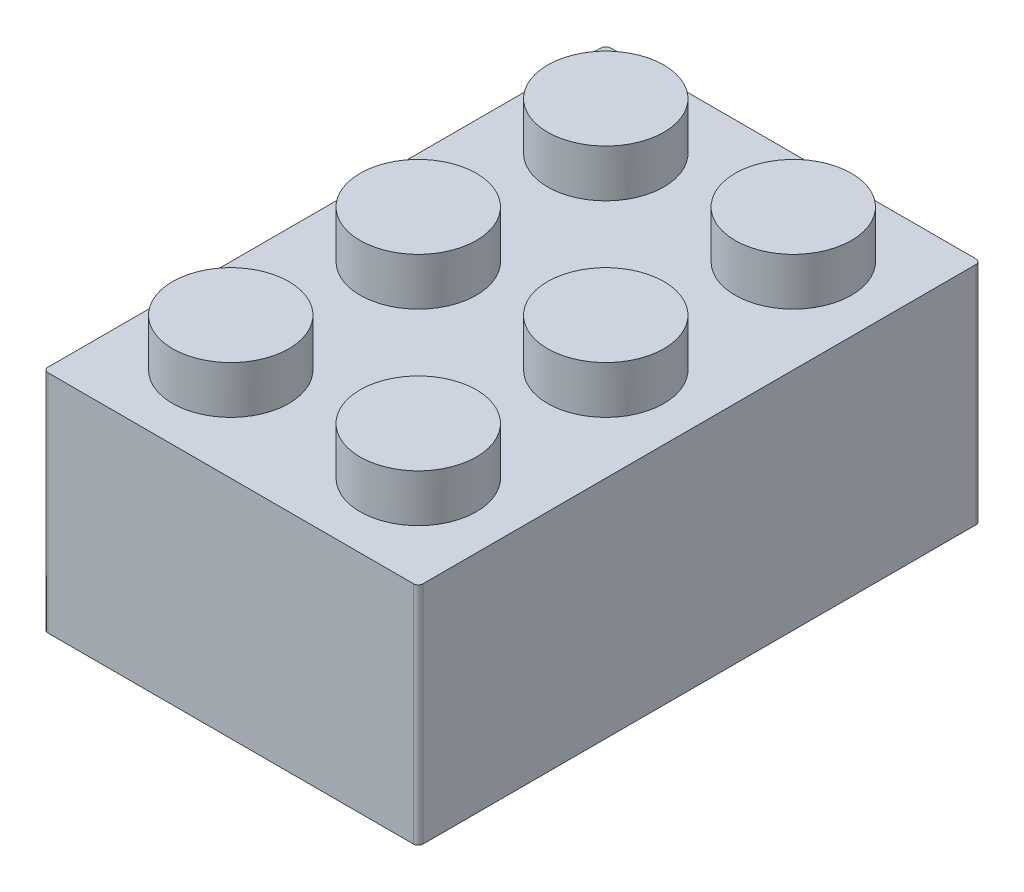
from build123d import *

# Parameters (mm, degrees)
SKETCH1_W           = 15.8
SKETCH1_H           = 23.7
BOSS_EXTRUDE1_DEPTH = 4.75
SKETCH2_R           = 2.45
BOSS_EXTRUDE2_DEPTH = 2
SKETCH4_W           = 12.8
SKETCH4_H           = 20.7
CUT_EXTRUDE1_DEPTH  = 4
SKETCH5_R           = 3.25
SKETCH5_R_2         = 2.45
BOSS_EXTRUDE3_DEPTH = 4
FILLET1_R           = 0.2


with BuildPart() as part:
    # Sketch1 → Boss-Extrude1 (new body, symmetric)
    with BuildSketch(Plane(origin=(0, 0, 0), x_dir=(1, 0, 0), z_dir=(0, 1, 0))):
        with Locations((7.9, 11.85)):
            Rectangle(SKETCH1_W, SKETCH1_H)
    extrude(amount=BOSS_EXTRUDE1_DEPTH, both=True)

    # Sketch2 → Boss-Extrude2 (add)
    with BuildSketch(Plane(origin=(0, 4.75, 0), x_dir=(1, 0, 0), z_dir=(0, 1, 0))):
        with Locations((3.95, 3.95)):
            Circle(SKETCH2_R)
        with Locations((11.85, 3.95)):
            Circle(SKETCH2_R)
        with Locations((11.85, 11.85)):
            Circle(SKETCH2_R)
        with Locations((3.95, 11.85)):
            Circle(SKETCH2_R)
        with Locations((3.95, 19.75)):
            Circle(SKETCH2_R)
        with Locations((11.85, 19.75)):
            Circle(SKETCH2_R)
    extrude(amount=BOSS_EXTRUDE2_DEPTH)

    # Sketch4 → Cut-Extrude1 (cut)
    with BuildSketch(Plane.XZ.offset(4.75)):
        with Locations((7.9, -11.85)):
            Rectangle(SKETCH4_W, SKETCH4_H)
    extrude(amount=-CUT_EXTRUDE1_DEPTH, mode=Mode.SUBTRACT)

    # Sketch5 → Boss-Extrude3 (add)
    with BuildSketch(Plane.XZ.offset(0.75)):
        with Locations((7.9, -15.8)):
            Circle(SKETCH5_R)
        with Locations((7.9, -15.8)):
            Circle(SKETCH5_R_2, mode=Mode.SUBTRACT)
        with Locations((7.9, -7.9)):
            Circle(SKETCH5_R)
        with Locations((7.9, -7.9)):
            Circle(SKETCH5_R_2, mode=Mode.SUBTRACT)
    extrude(amount=BOSS_EXTRUDE3_DEPTH)

    # Fillet1
    fillet1_edges = [part.edges().sort_by_distance(p)[0] for p in [
        (0, 0, -23.7),
        (15.8, 0, -23.7),
        (15.8, 0, 0),
        (0, 0, 0),
    ]]
    fillet(fillet1_edges, radius=FILLET1_R)


solid = part.part
